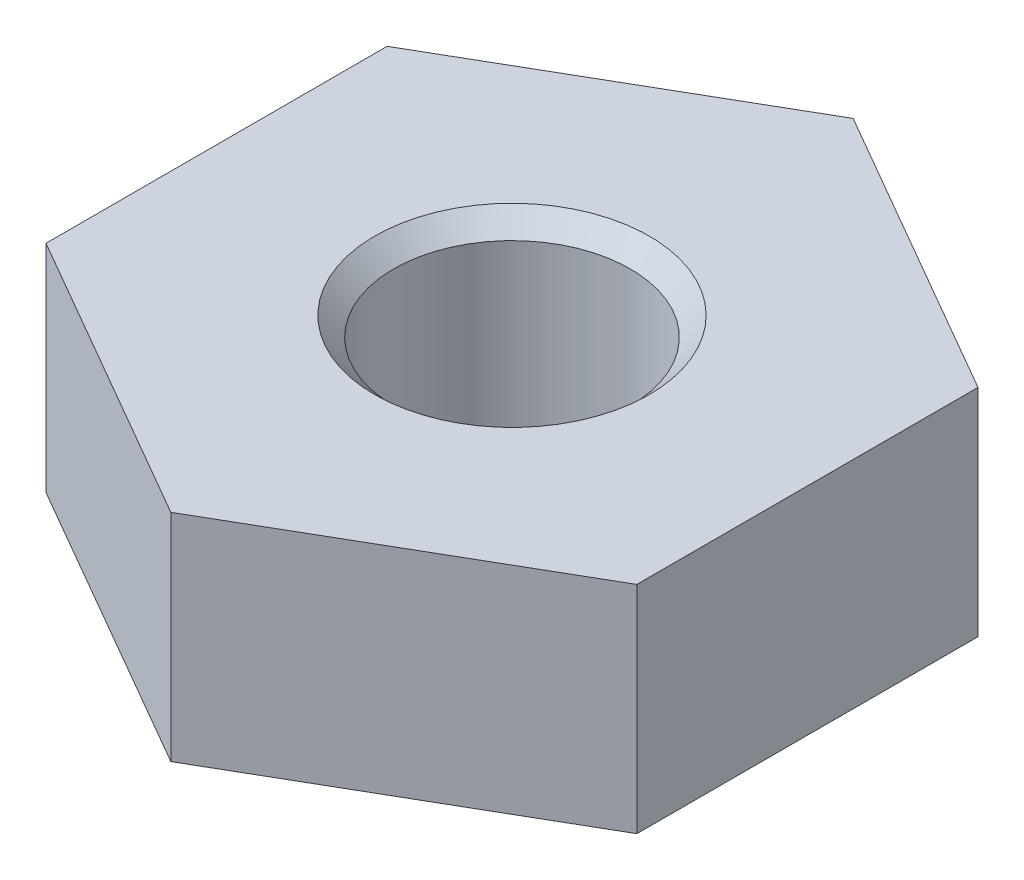
from build123d import *

# Parameters (mm, degrees)
BOSS_EXTRUDE1_DEPTH = 2.8956
SKETCH2_R           = 1.5875
CUT_EXTRUDE1_DEPTH  = 2.8956
CHAMFER3_SIZE       = 0.254
CHAMFER4_SIZE       = 0.254


with BuildPart() as part:
    # Sketch1 → Boss-Extrude1 (new body)
    with BuildSketch(Plane(origin=(0, 0, 0), x_dir=(1, 0, 0), z_dir=(0, 1, 0))):
        Polygon((0, -4.575385413), (3.9624, -2.287692707), (3.9624, 2.287692707), (0, 4.575385413), (-3.9624, 2.287692707), (-3.9624, -2.287692707), align=None)
    extrude(amount=BOSS_EXTRUDE1_DEPTH)

    # Sketch2 → Cut-Extrude1 (cut)
    with BuildSketch(Plane(origin=(0, 2.8956, 0), x_dir=(1, 0, 0), z_dir=(0, 1, 0))):
        Circle(SKETCH2_R)
    extrude(amount=-CUT_EXTRUDE1_DEPTH, mode=Mode.SUBTRACT)

    # Chamfer3
    chamfer3_edges = [part.edges().sort_by_distance(p)[0] for p in [
        (-1.5875, 2.8956, 0),
    ]]
    chamfer(chamfer3_edges, length=CHAMFER3_SIZE)

    # Chamfer4
    chamfer4_edges = [part.edges().sort_by_distance(p)[0] for p in [
        (-1.5875, 0, 0),
    ]]
    chamfer(chamfer4_edges, length=CHAMFER4_SIZE)


solid = part.part
